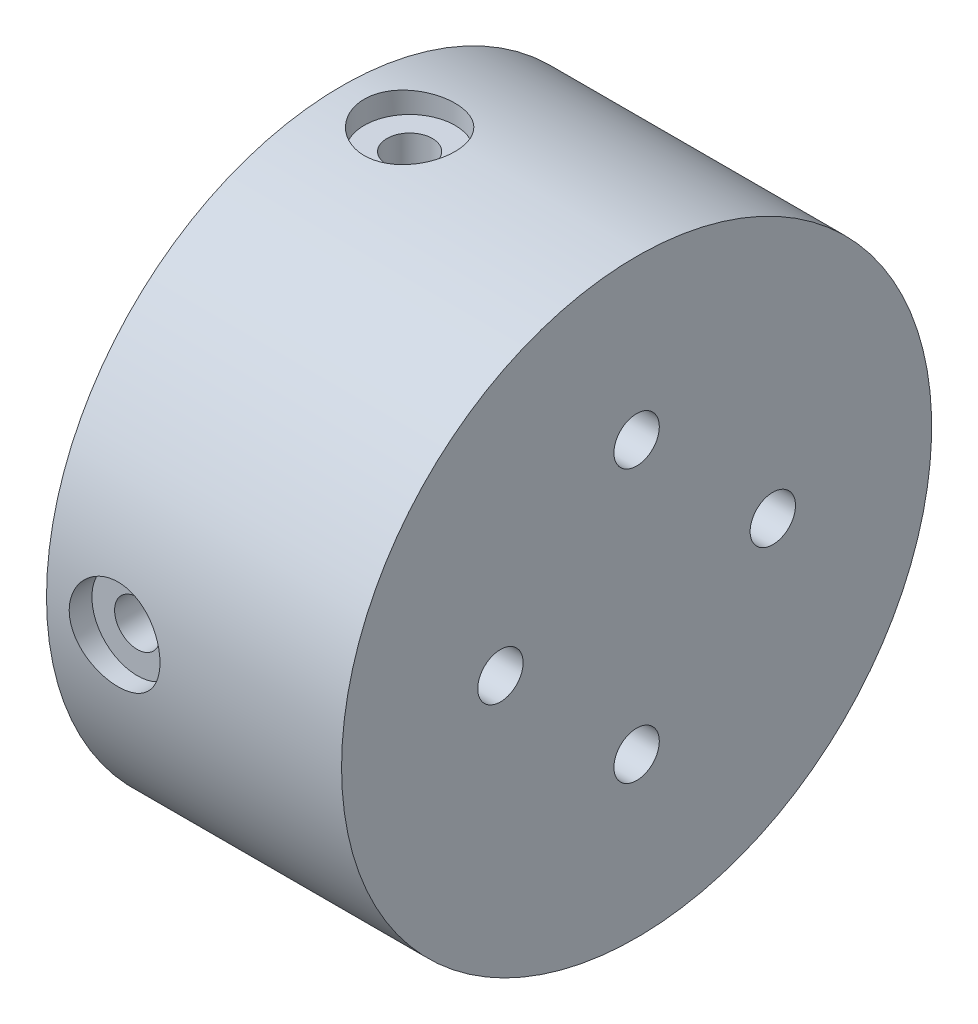
from build123d import *

# Parameters (mm, degrees)
CUT_EXTRUDE_1_REACH      = 24.517
SKETCH_2_R               = 1
PATTERN_CIRCULAR_1_COUNT = 4
SKETCH_5_R               = 1
CUT_EXTRUDE_2_DEPTH      = 10
PATTERN_CIRCULAR_3_COUNT = 4
SKETCH_7_R               = 2
CUT_EXTRUDE_3_DEPTH      = 1
PATTERN_CIRCULAR_4_COUNT = 4


with BuildPart() as part:
    # Эскиз1 → Повернуть1 (revolve)
    with BuildSketch(Plane.XY):
        Polygon((0, 13), (13, 13), (13, 0), (10, 0), (10, 10), (0, 10), align=None)
    revolve(axis=Axis((0, 0, 0), (1, 0, 0)))

    # Эскиз2 → Вырез-Вытянуть1 (cut, up to next)
    with BuildSketch(Plane(origin=(13, 0, 0), x_dir=(0, 0, -1), z_dir=(1, 0, 0)), mode=Mode.PRIVATE) as cut_extrude_1_sk1:
        with Locations((0, 6)):
            Circle(SKETCH_2_R)
    cut_extrude_1_tool1 = extrude(cut_extrude_1_sk1.sketch, amount=-CUT_EXTRUDE_1_REACH, mode=Mode.PRIVATE) & part.part
    cut_extrude_1 = cut_extrude_1_tool1.solids().sort_by_distance((13, 6, 0))[0]
    add(cut_extrude_1, mode=Mode.SUBTRACT)

    # Круговой массив1: Вырез-Вытянуть1 ×4 about axis
    pattern_circular_1_axis = Axis((10, 0, 0), (-1, 0, 0))
    for i in range(1, PATTERN_CIRCULAR_1_COUNT):
        add(cut_extrude_1.rotate(pattern_circular_1_axis, i * 360 / PATTERN_CIRCULAR_1_COUNT), mode=Mode.SUBTRACT)

    # Эскиз5 → Вырез-Вытянуть2 (cut)
    with BuildSketch(Plane.XY.offset(13)):
        with Locations((3, 0)):
            Circle(SKETCH_5_R)
    cut_extrude_2 = extrude(amount=-CUT_EXTRUDE_2_DEPTH, mode=Mode.SUBTRACT)

    # Круговой массив3: Вырез-Вытянуть2 ×4 about axis
    pattern_circular_3_axis = Axis((10, 0, 0), (-1, 0, 0))
    for i in range(1, PATTERN_CIRCULAR_3_COUNT):
        add(cut_extrude_2.rotate(pattern_circular_3_axis, i * 360 / PATTERN_CIRCULAR_3_COUNT), mode=Mode.SUBTRACT)

    # Эскиз7 → Вырез-Вытянуть3 (cut)
    with BuildSketch(Plane.XY.offset(13)):
        with Locations((3, 0)):
            Circle(SKETCH_7_R)
    cut_extrude_3 = extrude(amount=-CUT_EXTRUDE_3_DEPTH, mode=Mode.SUBTRACT)

    # Круговой массив4: Вырез-Вытянуть3 ×4 about axis
    pattern_circular_4_axis = Axis((10, 0, 0), (-1, 0, 0))
    for i in range(1, PATTERN_CIRCULAR_4_COUNT):
        add(cut_extrude_3.rotate(pattern_circular_4_axis, i * 360 / PATTERN_CIRCULAR_4_COUNT), mode=Mode.SUBTRACT)


solid = part.part
